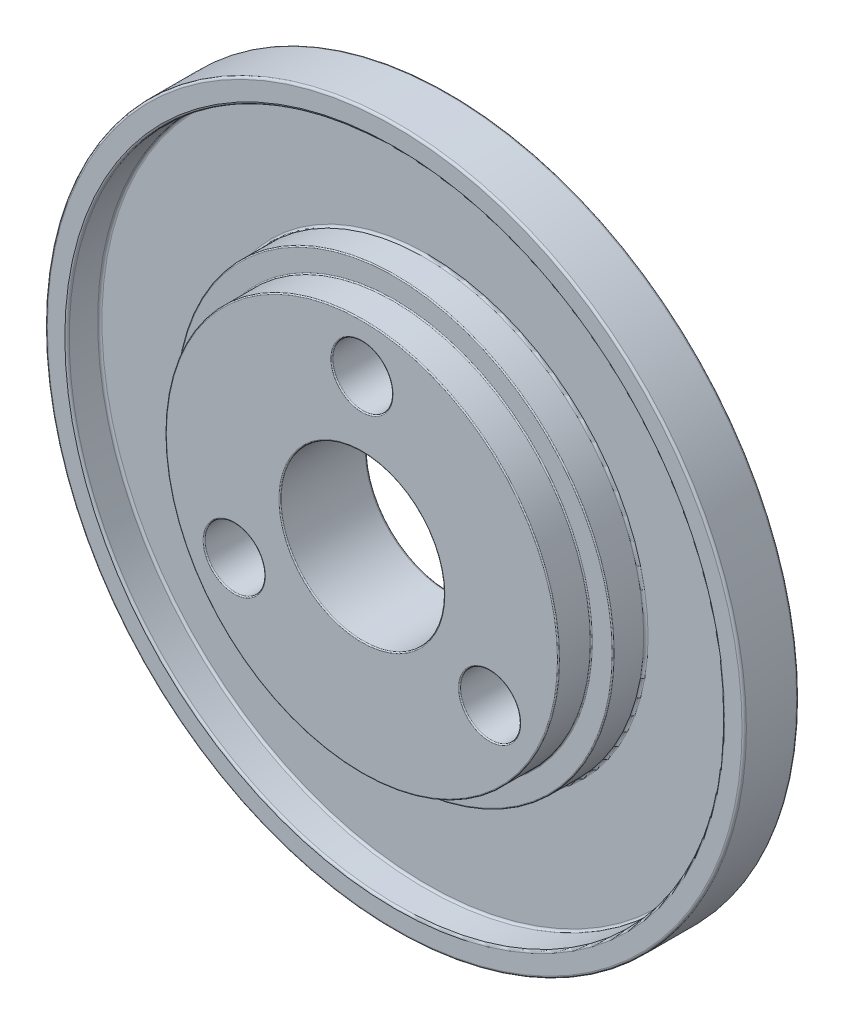
from build123d import *

# Parameters (mm, degrees)
CROQUIS1_R                                           = 32
CROQUIS1_R_2                                         = 7.5
SALIENTE_EXTRUIR1_DEPTH                              = 5
CROQUIS2_R                                           = 30
CROQUIS2_R_2                                         = 20
CORTAR_EXTRUIR1_DEPTH                                = 3
REDONDEO1_R                                          = 0.2
CROQUIS14_R                                          = 18
CROQUIS14_R_2                                        = 7.5
SALIENTE_EXTRUIR4_DEPTH                              = 3
CROQUIS18_R                                          = 2.75
CORTAR_EXTRUIR6_DEPTH                                = 8
REFRENTADO_PARA_TORNILLO_TAP_N_CON_CABEZ_D           = 5.5
REFRENTADO_PARA_TORNILLO_TAP_N_CON_CABEZ_CSINK_D     = 11.2
REFRENTADO_PARA_TORNILLO_TAP_N_CON_CABEZ_CSINK_ANGLE = 90
REDONDEO3_R                                          = 0.1


with BuildPart() as part:
    # Croquis1 → Saliente-Extruir1 (new body)
    with BuildSketch(Plane.XY):
        Circle(CROQUIS1_R)
        Circle(CROQUIS1_R_2, mode=Mode.SUBTRACT)
    extrude(amount=SALIENTE_EXTRUIR1_DEPTH)

    # Croquis2 → Cortar-Extruir1 (cut)
    with BuildSketch(Plane.XY.offset(5)):
        Circle(CROQUIS2_R)
        Circle(CROQUIS2_R_2, mode=Mode.SUBTRACT)
    extrude(amount=-CORTAR_EXTRUIR1_DEPTH, mode=Mode.SUBTRACT)

    # Redondeo1
    redondeo1_edges = [part.edges().sort_by_distance(p)[0] for p in [
        (-30, 0, 2),
        (-20, 0, 2),
        (-30, 0, 5),
        (-32, 0, 0),
        (-32, 0, 5),
        (-7.5, 0, 0),
    ]]
    fillet(redondeo1_edges, radius=REDONDEO1_R)

    # Croquis14 → Saliente-Extruir4 (add)
    with BuildSketch(Plane.XY.offset(5)):
        Circle(CROQUIS14_R)
        Circle(CROQUIS14_R_2, mode=Mode.SUBTRACT)
    extrude(amount=SALIENTE_EXTRUIR4_DEPTH)

    # Croquis18 → Cortar-Extruir6 (cut)
    with BuildSketch(Plane.XY.offset(8)):
        with Locations((0, 13.5)):
            Circle(CROQUIS18_R)
        with Locations((11.691342951, -6.75)):
            Circle(CROQUIS18_R)
        with Locations((-11.691342951, -6.75)):
            Circle(CROQUIS18_R)
    extrude(amount=-CORTAR_EXTRUIR6_DEPTH, mode=Mode.SUBTRACT)

    # Refrentado para tornillo tapón con cabeza plana de clavija de M54 (through all)
    with Locations(Plane(origin=(11.691342951, -6.75, 0), x_dir=(-1, 0, 0), z_dir=(0, 0, -1))):
        with Locations((0, 0), (23.382685902, 0), (11.691342951, 20.25)):
            CounterSinkHole(REFRENTADO_PARA_TORNILLO_TAP_N_CON_CABEZ_D / 2, REFRENTADO_PARA_TORNILLO_TAP_N_CON_CABEZ_CSINK_D / 2, counter_sink_angle=REFRENTADO_PARA_TORNILLO_TAP_N_CON_CABEZ_CSINK_ANGLE)

    # Redondeo3
    redondeo3_edges = [part.edges().sort_by_distance(p)[0] for p in [
        (-20, 0, 5),
        (-18, 0, 8),
        (-18, 0, 5),
        (-7.5, 0, 8),
        (-2.75, 13.5, 8),
        (-14.441342951, -6.75, 8),
        (8.941342951, -6.75, 8),
    ]]
    fillet(redondeo3_edges, radius=REDONDEO3_R)


solid = part.part
